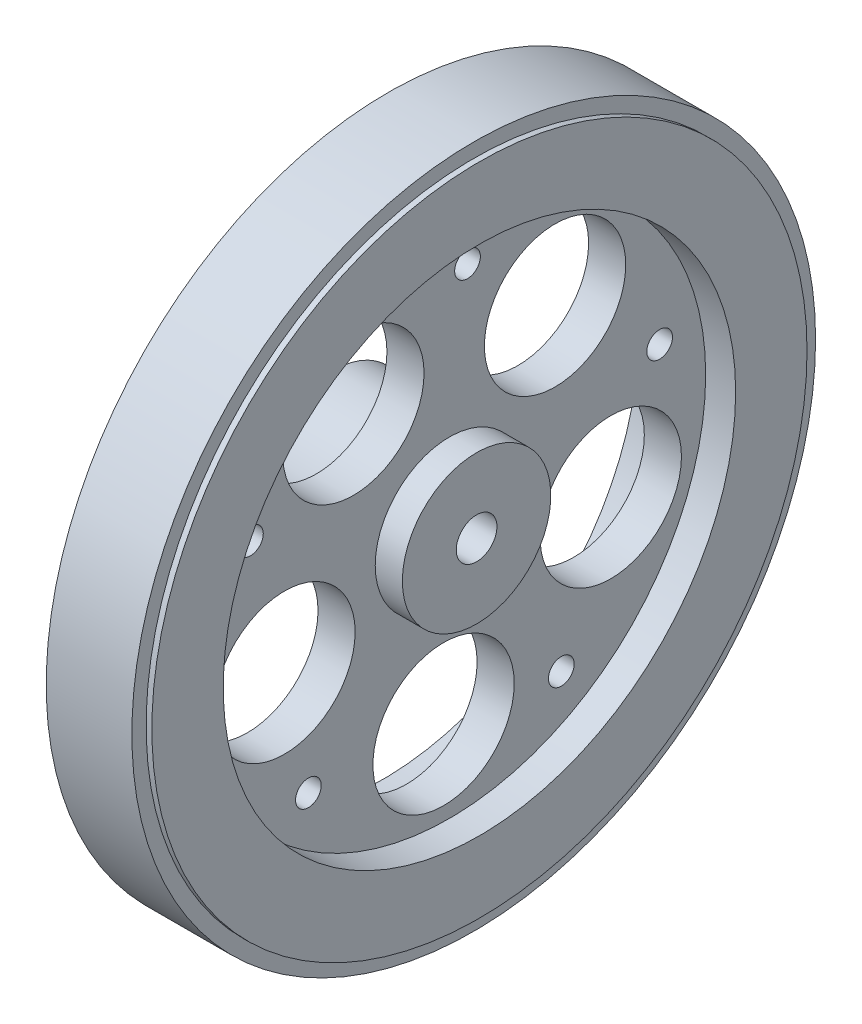
from build123d import *
from build123d.topology import SkipClean

# Parameters (mm, degrees)
SKETCH_3_R               = 45.9
EXTRUDE_3_DEPTH          = 2.6
SKETCH_4_R               = 45.9
SKETCH_4_R_2             = 35.9
EXTRUDE_4_DEPTH          = 6.8
SKETCH_5_R               = 2.85
CUT_EXTRUDE_3_DEPTH      = 6.8
SKETCH_13_R              = 10.4
SKETCH_13_R_2            = 2.85
EXTRUDE_5_DEPTH          = 11
EXTRUDE_START            = 3.8
SKETCH_14_R              = 10.4
SKETCH_14_R_2            = 2.85
EXTRUDE_6_DEPTH          = 3.8
SKETCH_17_R              = 9.9
CUT_EXTRUDE_5_DEPTH      = 67.321791291
PATTERN_CIRCULAR_1_COUNT = 5
SKETCH_19_R              = 1.8
CUT_EXTRUDE_6_DEPTH      = 67.321791291
PATTERN_CIRCULAR_2_COUNT = 5
SKETCH_20_R              = 47.9
SKETCH_20_R_2            = 45.9
EXTRUDE_7_DEPTH          = 6


with BuildPart() as part:
    # 草图3 → 凸台-拉伸3 (new, symmetric)
    with BuildSketch(Plane(origin=(0, 0, 0), x_dir=(0, 0, -1), z_dir=(1, 0, 0))):
        Circle(SKETCH_3_R)
    extrude(amount=EXTRUDE_3_DEPTH, both=True)

    # 草图4 → 凸台-拉伸4 (add, symmetric)
    with BuildSketch(Plane(origin=(0, 0, 0), x_dir=(0, 0, -1), z_dir=(1, 0, 0))):
        Circle(SKETCH_4_R)
        Circle(SKETCH_4_R_2, mode=Mode.SUBTRACT)
    extrude(amount=EXTRUDE_4_DEPTH, both=True)

    # 草图5 → 切除-拉伸3 (cut, symmetric)
    with BuildSketch(Plane(origin=(0, 0, 0), x_dir=(0, 0, -1), z_dir=(1, 0, 0))):
        Circle(SKETCH_5_R)
    extrude(amount=CUT_EXTRUDE_3_DEPTH, both=True, mode=Mode.SUBTRACT)

    # 草图13 → 凸台-拉伸5 (add)
    with SkipClean():  # the faces are left unmerged after this step: merging them gives an invalid solid
        with BuildSketch(Plane.ZY.offset(2.6)):
            Circle(SKETCH_13_R)
            Circle(SKETCH_13_R_2, mode=Mode.SUBTRACT)
        extrude(amount=EXTRUDE_5_DEPTH)

    # 草图14 → 凸台-拉伸6 (add)
    with SkipClean():  # the faces are left unmerged after this step: merging them gives an invalid solid
        with BuildSketch(Plane(origin=(2.6, 0, 0), x_dir=(0, 0, -1), z_dir=(1, 0, 0)).offset(EXTRUDE_START)):
            Circle(SKETCH_14_R)
            Circle(SKETCH_14_R_2, mode=Mode.SUBTRACT)
        extrude(amount=-EXTRUDE_6_DEPTH)

    # 草图17 → 切除-拉伸5 (cut, symmetric)
    with SkipClean():  # the faces are left unmerged after this step: merging them gives an invalid solid
        with BuildSketch(Plane(origin=(0, 0, 0), x_dir=(0, 0, -1), z_dir=(1, 0, 0))):
            with Locations((-13.45976737, 19.930809375)):
                Circle(SKETCH_17_R)
        cut_extrude_5 = extrude(amount=CUT_EXTRUDE_5_DEPTH, both=True, mode=Mode.SUBTRACT)

    # 阵列(圆周)1: 切除-拉伸5 ×5 about axis
    with SkipClean():  # the faces are left unmerged after this step: merging them gives an invalid solid
        pattern_circular_1_axis = Axis((7.82, 0, 0), (-1, 0, 0))
        for i in range(1, PATTERN_CIRCULAR_1_COUNT):
            add(cut_extrude_5.rotate(pattern_circular_1_axis, i * 360 / PATTERN_CIRCULAR_1_COUNT), mode=Mode.SUBTRACT)

    # 草图19 → 切除-拉伸6 (cut, symmetric)
    with SkipClean():  # the faces are left unmerged after this step: merging them gives an invalid solid
        with BuildSketch(Plane(origin=(0, 0, 0), x_dir=(0, 0, -1), z_dir=(1, 0, 0))):
            with Locations((-27.887163563, 11.720435504)):
                Circle(SKETCH_19_R)
        cut_extrude_6 = extrude(amount=CUT_EXTRUDE_6_DEPTH, both=True, mode=Mode.SUBTRACT)

    # 阵列(圆周)2: 切除-拉伸6 ×5 about axis
    with SkipClean():  # the faces are left unmerged after this step: merging them gives an invalid solid
        pattern_circular_2_axis = Axis((7.82, 0, 0), (-1, 0, 0))
        for i in range(1, PATTERN_CIRCULAR_2_COUNT):
            add(cut_extrude_6.rotate(pattern_circular_2_axis, i * 360 / PATTERN_CIRCULAR_2_COUNT), mode=Mode.SUBTRACT)

    # 草图20 → 凸台-拉伸7 (add, symmetric)
    with SkipClean():  # the faces are left unmerged after this step: merging them gives an invalid solid
        with BuildSketch(Plane(origin=(0, 0, 0), x_dir=(0, 0, -1), z_dir=(1, 0, 0))):
            Circle(SKETCH_20_R)
            Circle(SKETCH_20_R_2, mode=Mode.SUBTRACT)
        extrude(amount=EXTRUDE_7_DEPTH, both=True)


solid = part.part
